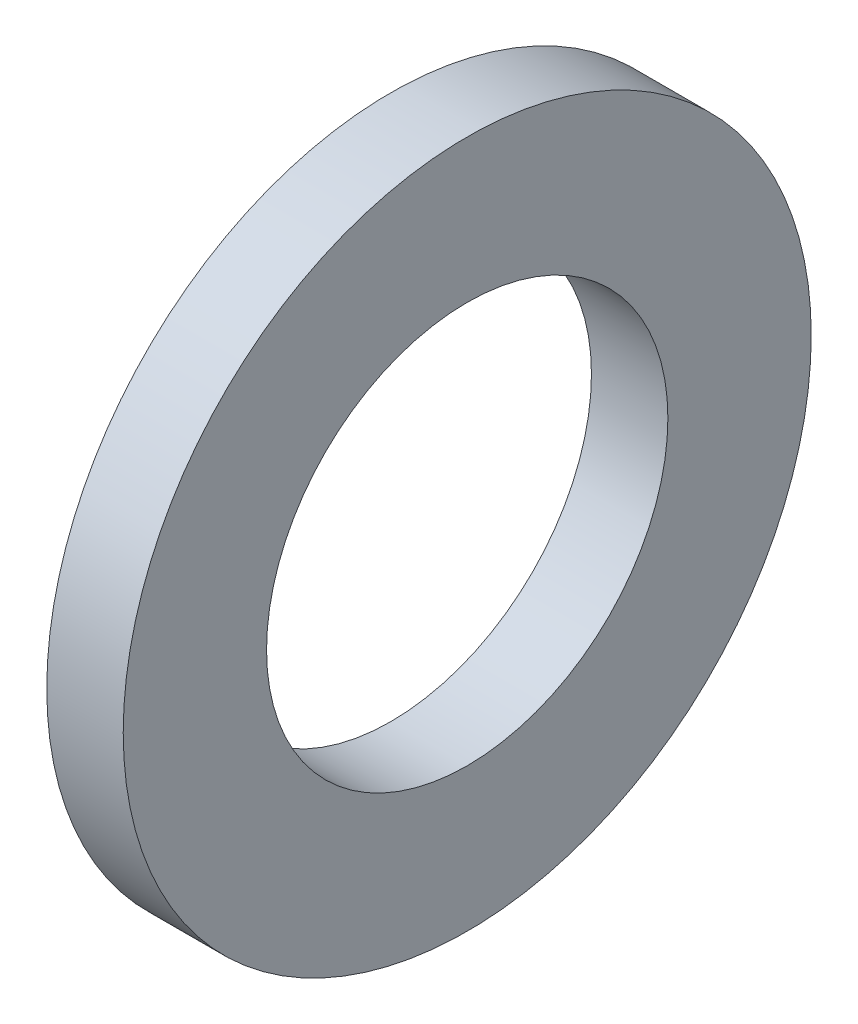
from build123d import *

# Parameters (mm, degrees)
SKETCH1_W = 2
SKETCH1_H = 3.75


with BuildPart() as part:
    # Sketch1 → Base-Revolve (revolve)
    with BuildSketch(Plane.XY):
        with Locations((-1, 7.125)):
            Rectangle(SKETCH1_W, SKETCH1_H)
    revolve(axis=Axis((-34.925, 0, 0), (1, 0, 0)))


solid = part.part
